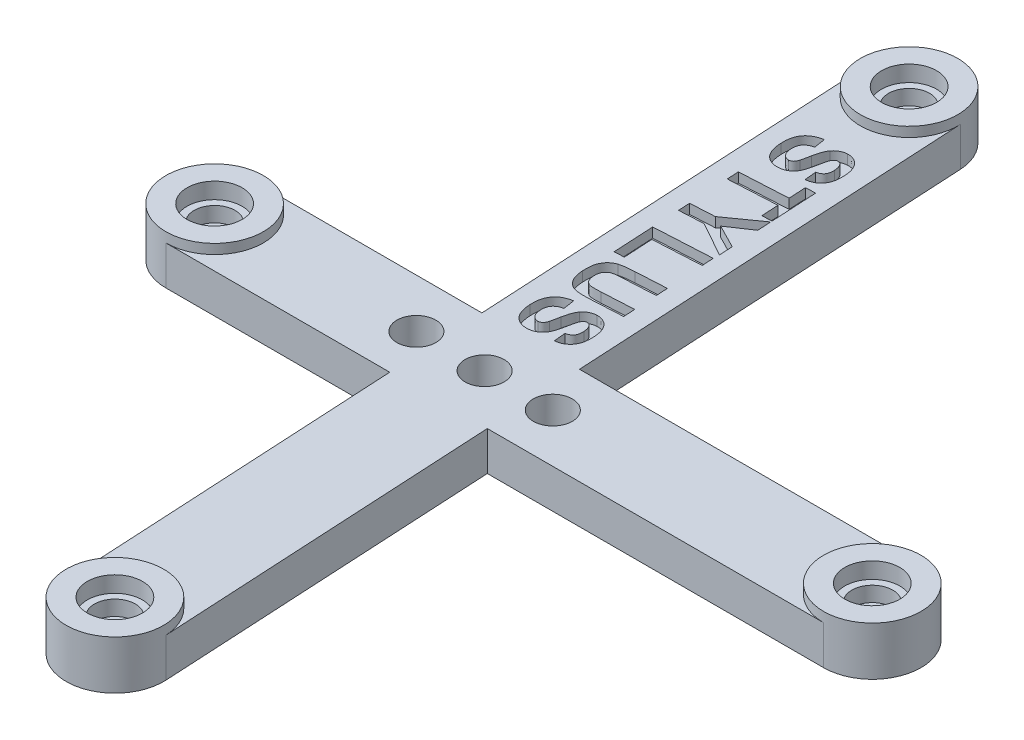
from build123d import *

# Parameters (mm, degrees)
BOSS_EXTRUDE1_DEPTH = 4
SKETCH2_R           = 5
BOSS_EXTRUDE2_DEPTH = 1
SKETCH3_R           = 1.5
CUT_EXTRUDE1_DEPTH  = 6
SKETCH4_R           = 2.1
CUT_EXTRUDE2_DEPTH  = 3.2
SKETCH5_R           = 2.825
CUT_EXTRUDE3_DEPTH  = 1.65
SKETCH6_R           = 2
CUT_EXTRUDE4_DEPTH  = 5
CUT_EXTRUDE5_DEPTH  = 1


with BuildPart() as part:
    # Sketch1 → Boss-Extrude1 (new body)
    with BuildSketch(Plane(origin=(0, 0, 0), x_dir=(1, 0, 0), z_dir=(0, 1, 0))):
        with BuildLine():
            Line((-9.628086501, 85.876730552), (-7.434079947, 45.10198834))
            Line((-7.434079947, 45.10198834), (-29.867807027, 45.10198834))
            ThreePointArc((-29.867807027, 45.10198834), (-34.867807027, 40.10198834), (-29.867807027, 35.10198834))
            Line((-29.867807027, 35.10198834), (-6.896000137, 35.10198834))
            Line((-6.896000137, 35.10198834), (-4.992777433, -0.268651273))
            ThreePointArc((-4.992777433, -0.268651273), (0.268651273, -4.992777433), (4.992777433, 0.268651273))
            Line((4.992777433, 0.268651273), (3.118465894, 35.10198834))
            Line((3.118465894, 35.10198834), (37.632192973, 35.10198834))
            ThreePointArc((37.632192973, 35.10198834), (42.632192973, 40.10198834), (37.632192973, 45.10198834))
            Line((37.632192973, 45.10198834), (2.580386084, 45.10198834))
            Line((2.580386084, 45.10198834), (0.357468365, 86.414033099))
            ThreePointArc((0.357468365, 86.414033099), (-4.903960341, 91.138159258), (-9.628086501, 85.876730552))
        make_face()
    extrude(amount=BOSS_EXTRUDE1_DEPTH)

    # Sketch2 → Boss-Extrude2 (add)
    with BuildSketch(Plane(origin=(0, 4, 0), x_dir=(1, 0, 0), z_dir=(0, 1, 0))):
        with Locations((-4.635309068, 86.145381825)):
            Circle(SKETCH2_R)
        with Locations((-29.867807027, 40.10198834)):
            Circle(SKETCH2_R)
        with Locations((37.632192973, 40.10198834)):
            Circle(SKETCH2_R)
        Circle(SKETCH2_R)
    extrude(amount=BOSS_EXTRUDE2_DEPTH)

    # Sketch3 → Cut-Extrude1 (cut, through all)
    with BuildSketch(Plane(origin=(0, 5, 0), x_dir=(1, 0, 0), z_dir=(0, 1, 0))):
        with Locations((-29.867807027, 40.10198834)):
            Circle(SKETCH3_R)
        with Locations((-4.635309068, 86.145381825)):
            Circle(SKETCH3_R)
        with Locations((37.632192973, 40.10198834)):
            Circle(SKETCH3_R)
        Circle(SKETCH3_R)
    extrude(amount=-CUT_EXTRUDE1_DEPTH, mode=Mode.SUBTRACT)

    # Sketch4 → Cut-Extrude2 (cut)
    with BuildSketch(Plane(origin=(0, 5, 0), x_dir=(1, 0, 0), z_dir=(0, 1, 0))):
        with Locations((-4.635309068, 86.145381825)):
            Circle(SKETCH4_R)
        with Locations((-29.867807027, 40.10198834)):
            Circle(SKETCH4_R)
        with Locations((37.632192973, 40.10198834)):
            Circle(SKETCH4_R)
        Circle(SKETCH4_R)
    extrude(amount=-CUT_EXTRUDE2_DEPTH, mode=Mode.SUBTRACT)

    # Sketch5 → Cut-Extrude3 (cut)
    with BuildSketch(Plane(origin=(0, 5, 0), x_dir=(1, 0, 0), z_dir=(0, 1, 0))):
        with Locations((-4.635309068, 86.145381825)):
            Circle(SKETCH5_R)
        with Locations((-29.867807027, 40.10198834)):
            Circle(SKETCH5_R)
        with Locations((37.632192973, 40.10198834)):
            Circle(SKETCH5_R)
        Circle(SKETCH5_R)
    extrude(amount=-CUT_EXTRUDE3_DEPTH, mode=Mode.SUBTRACT)

    # Sketch6 → Cut-Extrude4 (cut, through all)
    with BuildSketch(Plane(origin=(0, 4, 0), x_dir=(1, 0, 0), z_dir=(0, 1, 0))):
        with Locations((-2.157807027, 40.10198834)):
            Circle(SKETCH6_R)
        with Locations((4.842192973, 40.10198834)):
            Circle(SKETCH6_R)
        with Locations((-9.157807027, 40.10198834)):
            Circle(SKETCH6_R)
    extrude(amount=-CUT_EXTRUDE4_DEPTH, mode=Mode.SUBTRACT)

    # Sketch7 → Cut-Extrude5 (cut)
    with BuildSketch(Plane(origin=(0, 4, 0), x_dir=(1, 0, 0), z_dir=(0, 1, 0))):
        with BuildLine():
            Line((-5.264074732, 78.076081163), (-5.088593962, 76.913821548))
            add(Edge.make_bspline(
                [(-5.088593962, 76.913821548), (-5.135633909, 76.901996916), (-5.226917461, 76.87905058), (-5.357629783, 76.835678309), (-5.47795541, 76.785016988), (-5.588836743, 76.729004059), (-5.689252964, 76.666032193), (-5.77984549, 76.597777554), (-5.86018822, 76.522546335), (-5.929979434, 76.440461103), (-5.990516975, 76.352298032), (-6.041369582, 76.257461765), (-6.083163077, 76.156279746), (-6.11731267, 76.048674834), (-6.141070944, 75.934283827), (-6.155035224, 75.81322286), (-6.161283992, 75.685896766), (-6.158517857, 75.598917581), (-6.157103578, 75.554446548)],
                knots=[0, 0, 0, 0, 0.000145477, 0.000282307, 0.00041267, 0.000536841, 0.000654562, 0.000767785, 0.000876624, 0.000984046, 0.001090395, 0.001196872, 0.001306247, 0.001418387, 0.001535072, 0.001656127, 0.001783672, 0.001917108, 0.001917108, 0.001917108, 0.001917108], degree=3))
            add(Edge.make_bspline(
                [(-6.157103578, 75.554446548), (-6.154283879, 75.507486495), (-6.148840724, 75.416834661), (-6.128067459, 75.285895723), (-6.104701418, 75.16359605), (-6.069780222, 75.051206914), (-6.03132776, 74.947587235), (-5.983447645, 74.853475863), (-5.929003994, 74.768571214), (-5.866717542, 74.69369055), (-5.801446431, 74.627703589), (-5.732029347, 74.571938925), (-5.66101456, 74.525292335), (-5.588678173, 74.485186043), (-5.512386235, 74.458541558), (-5.435291684, 74.438679966), (-5.355679262, 74.428556946), (-5.302156512, 74.429942613), (-5.274892039, 74.430648471)],
                knots=[0, 0, 0, 0, 0.00014104, 0.000272265, 0.000397432, 0.000514167, 0.000624882, 0.000728624, 0.000830305, 0.000926796, 0.001020284, 0.00110832, 0.001193326, 0.001275057, 0.001355666, 0.001434957, 0.001513671, 0.001595402, 0.001595402, 0.001595402, 0.001595402], degree=3))
            add(Edge.make_bspline(
                [(-5.274892039, 74.430648471), (-5.241062727, 74.433964345), (-5.17514334, 74.440425617), (-5.081087182, 74.468222598), (-4.996373817, 74.512954554), (-4.918400714, 74.572657176), (-4.850505115, 74.654339099), (-4.787332788, 74.755336833), (-4.733234893, 74.880193602), (-4.703921355, 74.972023734), (-4.688353578, 75.020792702)],
                knots=[0, 0, 0, 0, 0.000101824, 0.000198412, 0.000291954, 0.000387882, 0.000491003, 0.000608724, 0.000744307, 0.000897861, 0.000897861, 0.000897861, 0.000897861], degree=3))
            add(Edge.make_bspline(
                [(-4.688353578, 75.020792702), (-4.682638545, 75.041598823), (-4.669819444, 75.088267986), (-4.650964673, 75.167396042), (-4.627370712, 75.263202894), (-4.604721286, 75.377072426), (-4.576255378, 75.507018603), (-4.546388777, 75.6540992), (-4.514033943, 75.818383043), (-4.491979151, 75.933841844), (-4.480420886, 75.994350394)],
                knots=[0, 0, 0, 0, 6.4726e-05, 0.000145183, 0.000244011, 0.000360697, 0.000493415, 0.000643097, 0.000810928, 0.000995735, 0.000995735, 0.000995735, 0.000995735], degree=3))
            add(Edge.make_bspline(
                [(-4.480420886, 75.994350394), (-4.46446382, 76.072976278), (-4.433585579, 76.225123864), (-4.381315452, 76.443493903), (-4.323591993, 76.644049764), (-4.261236287, 76.826479611), (-4.195849085, 76.991970341), (-4.124544422, 77.139226702), (-4.050410664, 77.269709775), (-3.993190265, 77.346214659), (-3.965997809, 77.382571548)],
                knots=[0, 0, 0, 0, 0.000240676, 0.000465728, 0.000673421, 0.000866508, 0.001043945, 0.001206827, 0.001357106, 0.001493194, 0.001493194, 0.001493194, 0.001493194], degree=3))
            add(Edge.make_bspline(
                [(-3.965997809, 77.382571548), (-3.927197208, 77.428237668), (-3.850748758, 77.518213185), (-3.723135312, 77.637309851), (-3.587228969, 77.738778577), (-3.445382719, 77.8252605), (-3.294434318, 77.892693246), (-3.136642474, 77.944503516), (-2.970617114, 77.980303339), (-2.856791274, 77.989616342), (-2.798930501, 77.994350394)],
                knots=[0, 0, 0, 0, 0.000179666, 0.000353995, 0.000522264, 0.000687785, 0.000851317, 0.001017035, 0.001185347, 0.00135936, 0.00135936, 0.00135936, 0.00135936], degree=3))
            add(Edge.make_bspline(
                [(-2.798930501, 77.994350394), (-2.723849216, 77.995628786), (-2.574651269, 77.998169144), (-2.353671463, 77.957896459), (-2.138249798, 77.889712295), (-1.967301794, 77.803691519), (-1.835534622, 77.721837321), (-1.7409826, 77.651557373), (-1.65265926, 77.573483017), (-1.56869441, 77.488705584), (-1.490901703, 77.396161414), (-1.418129022, 77.296008477), (-1.352918597, 77.187508117), (-1.269151141, 77.032890837), (-1.181348523, 76.820147084), (-1.102999497, 76.541708002), (-1.047200029, 76.237422326), (-1.030920182, 76.025030016), (-1.022488193, 75.915023471)],
                knots=[0, 0, 0, 0, 0.000224789, 0.000446689, 0.000670189, 0.000900786, 0.001018507, 0.001135335, 0.001253716, 0.001371854, 0.001492968, 0.001616064, 0.001742837, 0.001872433, 0.002143421, 0.00243102, 0.002738909, 0.003069715, 0.003069715, 0.003069715, 0.003069715], degree=3))
            add(Edge.make_bspline(
                [(-1.022488193, 75.915023471), (-1.018848026, 75.824490789), (-1.011775872, 75.64860297), (-1.021843541, 75.392781545), (-1.046713158, 75.153403044), (-1.086543329, 74.929838904), (-1.145372489, 74.72301954), (-1.220313906, 74.532622284), (-1.310025504, 74.358077577), (-1.41779823, 74.201606084), (-1.538666436, 74.061296008), (-1.67148342, 73.93709025), (-1.814949231, 73.828172882), (-1.970046806, 73.735947364), (-2.136966403, 73.661635474), (-2.314548432, 73.602895492), (-2.502745628, 73.558578712), (-2.632851135, 73.543900002), (-2.699170886, 73.536417702)],
                knots=[0, 0, 0, 0, 0.00027173, 0.00052792, 0.000767236, 0.000993316, 0.001208272, 0.001411155, 0.0016063, 0.001795659, 0.001979738, 0.002160862, 0.00234019, 0.002519111, 0.002700948, 0.002887187, 0.003079615, 0.003279688, 0.003279688, 0.003279688, 0.003279688], degree=3))
            Line((-2.699170886, 73.536417702), (-2.816959347, 74.73473501))
            add(Edge.make_bspline(
                [(-2.816959347, 74.73473501), (-2.780337673, 74.743360156), (-2.709169164, 74.760121782), (-2.608163334, 74.794279487), (-2.515222471, 74.832484993), (-2.430665222, 74.875731346), (-2.354541065, 74.923899197), (-2.286303539, 74.976867689), (-2.227305444, 75.036096387), (-2.176081386, 75.100611762), (-2.132179589, 75.171610177), (-2.095231837, 75.249443153), (-2.064987643, 75.335275634), (-2.040817032, 75.428058178), (-2.026343999, 75.529299025), (-2.01491158, 75.637098503), (-2.011468, 75.752792581), (-2.014775012, 75.832101273), (-2.016478578, 75.872956163)],
                knots=[0, 0, 0, 0, 0.000112814, 0.000219237, 0.000319459, 0.000414068, 0.000503763, 0.000589361, 0.00067265, 0.000753929, 0.000835977, 0.000922532, 0.001011872, 0.001108655, 0.00120963, 0.001318343, 0.001433784, 0.001556433, 0.001556433, 0.001556433, 0.001556433], degree=3))
            add(Edge.make_bspline(
                [(-2.016478578, 75.872956163), (-2.019778161, 75.915442866), (-2.026174742, 75.997807714), (-2.040566244, 76.117855194), (-2.066149381, 76.229697532), (-2.093020208, 76.335364729), (-2.130805135, 76.432152471), (-2.170451836, 76.523387542), (-2.219836084, 76.605880274), (-2.25763471, 76.65611564), (-2.276093962, 76.680648471)],
                knots=[0, 0, 0, 0, 0.000127862, 0.000247874, 0.000362209, 0.000471841, 0.000574533, 0.000673508, 0.000769977, 0.000862055, 0.000862055, 0.000862055, 0.000862055], degree=3))
            add(Edge.make_bspline(
                [(-2.276093962, 76.680648471), (-2.301339888, 76.708430797), (-2.350153148, 76.762148212), (-2.442605465, 76.819625061), (-2.546522395, 76.850717745), (-2.618839257, 76.851116954), (-2.655901655, 76.851321548)],
                knots=[0, 0, 0, 0, 0.000112185, 0.000216911, 0.000322249, 0.000432989, 0.000432989, 0.000432989, 0.000432989], degree=3))
            add(Edge.make_bspline(
                [(-2.655901655, 76.851321548), (-2.68996058, 76.847387586), (-2.756999949, 76.839644231), (-2.851537066, 76.798371909), (-2.93703276, 76.73643314), (-2.983120813, 76.681370106), (-3.006863193, 76.65300424)],
                knots=[0, 0, 0, 0, 0.000102354, 0.000201467, 0.000305564, 0.000416167, 0.000416167, 0.000416167, 0.000416167], degree=3))
            add(Edge.make_bspline(
                [(-3.006863193, 76.65300424), (-3.022257152, 76.630097981), (-3.056064788, 76.579792111), (-3.098332115, 76.488673593), (-3.140825454, 76.378447567), (-3.184435631, 76.247869), (-3.225609857, 76.096825648), (-3.266368159, 75.925155002), (-3.306870634, 75.733519769), (-3.346124793, 75.526861138), (-3.385226855, 75.317791113), (-3.425576807, 75.117143069), (-3.469415465, 74.931513763), (-3.511997366, 74.758811454), (-3.557281687, 74.600830361), (-3.604877217, 74.457303495), (-3.650602013, 74.327039128), (-3.715646251, 74.175221354), (-3.806758713, 74.002731155), (-3.939442949, 73.817946848), (-4.094257218, 73.655098917), (-4.239497006, 73.536833442), (-4.366879167, 73.455800197), (-4.46869203, 73.40106562), (-4.576404846, 73.35426897), (-4.691068745, 73.316405039), (-4.810550061, 73.281826775), (-4.936945284, 73.257519625), (-5.068912454, 73.23882872), (-5.159048029, 73.232940817), (-5.205180501, 73.229927317)],
                knots=[0, 0, 0, 0, 8.2688e-05, 0.000181597, 0.000300339, 0.000437168, 0.000594344, 0.000769842, 0.000966443, 0.001181893, 0.001400884, 0.001604545, 0.001795802, 0.00197304, 0.002138137, 0.002288651, 0.002426663, 0.00255213, 0.002783889, 0.003010378, 0.003232278, 0.003456217, 0.003570248, 0.003684784, 0.003802677, 0.003922025, 0.00404684, 0.004175541, 0.004307785, 0.004446429, 0.004446429, 0.004446429, 0.004446429], degree=3))
            add(Edge.make_bspline(
                [(-5.205180501, 73.229927317), (-5.24764681, 73.228544502), (-5.331818879, 73.225803638), (-5.457604219, 73.231948789), (-5.581790982, 73.247504983), (-5.704560197, 73.273168383), (-5.825868302, 73.306702444), (-5.945747386, 73.348839156), (-6.06341828, 73.401111939), (-6.179551764, 73.460392748), (-6.291342843, 73.528967461), (-6.397428335, 73.605679846), (-6.495519387, 73.691374499), (-6.587925674, 73.783343151), (-6.67343461, 73.883189745), (-6.751449992, 73.991566885), (-6.822245306, 74.107627013), (-6.887804994, 74.230438629), (-6.945107352, 74.362156673), (-6.996856464, 74.501803023), (-7.042326136, 74.649931597), (-7.082067443, 74.805881281), (-7.114357706, 74.970471887), (-7.140326215, 75.142947471), (-7.161518668, 75.324088488), (-7.168932646, 75.447824755), (-7.172728578, 75.511177317)],
                knots=[0, 0, 0, 0, 0.000127427, 0.000252571, 0.000377351, 0.000502519, 0.000628491, 0.000754699, 0.000883327, 0.001014491, 0.001145594, 0.001276378, 0.001406746, 0.001535929, 0.001667209, 0.001800644, 0.001936078, 0.002074794, 0.002217944, 0.002366638, 0.002521369, 0.002682575, 0.002849227, 0.003024312, 0.003205755, 0.003396118, 0.003396118, 0.003396118, 0.003396118], degree=3))
            add(Edge.make_bspline(
                [(-7.172728578, 75.511177317), (-7.176470143, 75.602515725), (-7.183758197, 75.780430366), (-7.172186826, 76.039890823), (-7.145630318, 76.284384679), (-7.099659229, 76.512568519), (-7.038994428, 76.726313513), (-6.959320717, 76.923926282), (-6.863348298, 77.107193138), (-6.747774071, 77.273433375), (-6.618011379, 77.426512666), (-6.469521253, 77.561909533), (-6.308306593, 77.686332754), (-6.128841586, 77.792216721), (-5.93559184, 77.887104059), (-5.726207089, 77.965782858), (-5.500942976, 78.029927488), (-5.344467809, 78.060416607), (-5.264074732, 78.076081163)],
                knots=[0, 0, 0, 0, 0.000274133, 0.000533974, 0.000778331, 0.001011219, 0.00123146, 0.001443939, 0.001649327, 0.001850695, 0.002050156, 0.002250026, 0.002452435, 0.002660006, 0.002873948, 0.003097622, 0.003330079, 0.003575707, 0.003575707, 0.003575707, 0.003575707], degree=3))
        make_face()
        Polygon((-6.812645629, 70.798023853), (-1.87153986, 71.066052699), (-1.967693706, 72.830475776), (-0.961684091, 72.884562315), (-0.705674475, 68.159802699), (-1.711684091, 68.105716161), (-1.806636014, 69.865331545), (-6.747741783, 69.597302699), align=None)
        Polygon((-6.527842029, 65.506078691), (-4.025438182, 65.641895998), (-0.699717029, 68.006078691), (-0.622793952, 66.598626768), (-2.900438182, 65.07218446), (-0.472553567, 63.828194075), (-0.398034336, 62.444780614), (-3.967745875, 64.443578691), (-6.462938182, 64.308963306), align=None)
        Polygon((-6.313191772, 61.504463688), (-0.415355234, 61.824175227), (-0.350451387, 60.623454073), (-5.24588408, 60.357829073), (-5.084826387, 57.37225215), (-6.087230234, 57.318165611), align=None)
        with BuildLine():
            Line((-0.095695864, 56.797855064), (-0.030792018, 55.59713391))
            Line((-0.030792018, 55.59713391), (-3.251945864, 55.422855064))
            add(Edge.make_bspline(
                [(-3.251945864, 55.422855064), (-3.312844647, 55.419278863), (-3.429452808, 55.412431202), (-3.595794567, 55.402197763), (-3.745196998, 55.389885887), (-3.877404027, 55.37784669), (-3.99294871, 55.36654252), (-4.091405677, 55.352840739), (-4.173498004, 55.340798347), (-4.221951832, 55.329382023), (-4.243532402, 55.324297372)],
                knots=[0, 0, 0, 0, 0.000183012, 0.000350429, 0.000499952, 0.000632708, 0.000748717, 0.000848158, 0.000930951, 0.000997438, 0.000997438, 0.000997438, 0.000997438], degree=3))
            add(Edge.make_bspline(
                [(-4.243532402, 55.324297372), (-4.301264155, 55.305916711), (-4.414523662, 55.269857101), (-4.568694812, 55.180895522), (-4.702567351, 55.066343863), (-4.796047988, 54.950869421), (-4.858238422, 54.846759565), (-4.899485137, 54.76181204), (-4.931097238, 54.669467341), (-4.958467207, 54.5722016), (-4.975403485, 54.467748052), (-4.988181996, 54.35748541), (-4.990967269, 54.240546601), (-4.988689912, 54.160826378), (-4.987522787, 54.119970449)],
                knots=[0, 0, 0, 0, 0.000181347, 0.000355771, 0.00052968, 0.000707443, 0.000798552, 0.000893168, 0.000990108, 0.001090991, 0.001195917, 0.001307145, 0.001423787, 0.001546407, 0.001546407, 0.001546407, 0.001546407], degree=3))
            add(Edge.make_bspline(
                [(-4.987522787, 54.119970449), (-4.984973868, 54.078633815), (-4.980031337, 53.998479212), (-4.962091347, 53.883150256), (-4.941828269, 53.775440019), (-4.911839698, 53.676739947), (-4.879465321, 53.584613638), (-4.837802789, 53.501969972), (-4.792688026, 53.425983687), (-4.722353314, 53.339883777), (-4.62594107, 53.247772097), (-4.496395076, 53.162195904), (-4.356646162, 53.101378708), (-4.230021462, 53.076838149), (-4.120316224, 53.065870255), (-4.024397054, 53.0621827), (-3.916249039, 53.057609523), (-3.795607816, 53.05882397), (-3.6625852, 53.059412308), (-3.517138179, 53.063336565), (-3.35927434, 53.069309061), (-3.249936556, 53.074962065), (-3.193051633, 53.077903141)],
                knots=[0, 0, 0, 0, 0.000124171, 0.000240776, 0.000349913, 0.000452605, 0.000549954, 0.000642408, 0.00072981, 0.000814467, 0.000975152, 0.001127829, 0.001278075, 0.001429178, 0.001512536, 0.00160881, 0.001717043, 0.001837236, 0.001970655, 0.002116132, 0.002273699, 0.002444579, 0.002444579, 0.002444579, 0.002444579], degree=3))
            Line((-3.193051633, 53.077903141), (0.096611828, 53.255787756))
            Line((0.096611828, 53.255787756), (0.161515675, 52.055066603))
            Line((0.161515675, 52.055066603), (-2.962282402, 51.885595449))
            add(Edge.make_bspline(
                [(-2.962282402, 51.885595449), (-3.048411234, 51.88138223), (-3.213822553, 51.8732907), (-3.452225051, 51.864931775), (-3.670984007, 51.859679972), (-3.870575286, 51.859228928), (-4.050868762, 51.864710547), (-4.212058614, 51.870925802), (-4.353713373, 51.882400136), (-4.513893436, 51.90472713), (-4.695099077, 51.942713849), (-4.895645628, 52.013385072), (-5.081337045, 52.103170601), (-5.250490798, 52.2167534), (-5.404428068, 52.352216787), (-5.541614445, 52.511916511), (-5.666351333, 52.692395002), (-5.756843358, 52.860058594), (-5.819638599, 53.006915712), (-5.863717121, 53.126558449), (-5.899981637, 53.255909749), (-5.933940902, 53.393190332), (-5.961739948, 53.539626698), (-5.982237967, 53.694646578), (-6.00134451, 53.858013986), (-6.008103205, 53.970082978), (-6.011561248, 54.027422372)],
                knots=[0, 0, 0, 0, 0.000258693, 0.000496822, 0.000715625, 0.000915144, 0.001095497, 0.001256716, 0.001399051, 0.001521606, 0.001741798, 0.001953145, 0.002157945, 0.002358957, 0.00256248, 0.002771203, 0.002988914, 0.003219614, 0.003341294, 0.003467907, 0.003601802, 0.003744061, 0.003892098, 0.004048648, 0.004213101, 0.004385395, 0.004385395, 0.004385395, 0.004385395], degree=3))
            add(Edge.make_bspline(
                [(-6.011561248, 54.027422372), (-6.014854642, 54.096316027), (-6.021247447, 54.230045458), (-6.022505585, 54.424512698), (-6.01632591, 54.606507378), (-6.004999151, 54.775815532), (-5.98599134, 54.932757393), (-5.959543059, 55.076757466), (-5.927742967, 55.208785947), (-5.875154963, 55.365184542), (-5.795396728, 55.542219513), (-5.685475676, 55.735989379), (-5.558409068, 55.907288633), (-5.416041971, 56.055100388), (-5.263882467, 56.181074507), (-5.104779125, 56.285188022), (-4.941839475, 56.370136778), (-4.827456799, 56.407886625), (-4.771176633, 56.426460833)],
                knots=[0, 0, 0, 0, 0.000206902, 0.000401617, 0.000583207, 0.000753104, 0.000910533, 0.001057167, 0.001192136, 0.001317563, 0.00155163, 0.001773462, 0.001984761, 0.002189629, 0.002387687, 0.002576037, 0.002759333, 0.00293688, 0.00293688, 0.00293688, 0.00293688], degree=3))
            add(Edge.make_bspline(
                [(-4.771176633, 56.426460833), (-4.726801591, 56.438467012), (-4.632962481, 56.463856264), (-4.483297246, 56.495620303), (-4.318027331, 56.524170882), (-4.137651667, 56.550399147), (-3.942143427, 56.574592823), (-3.730864692, 56.594468772), (-3.504524199, 56.612898631), (-3.348123981, 56.621532985), (-3.267570864, 56.625980064)],
                knots=[0, 0, 0, 0, 0.000137892, 0.000291597, 0.000458768, 0.000640985, 0.000838368, 0.001049694, 0.001277572, 0.001519589, 0.001519589, 0.001519589, 0.001519589], degree=3))
            Line((-3.267570864, 56.625980064), (-0.095695864, 56.797855064))
        make_face()
        with BuildLine():
            Line((-3.800958567, 50.884647145), (-3.625477798, 49.722387529))
            add(Edge.make_bspline(
                [(-3.625477798, 49.722387529), (-3.672517744, 49.710562897), (-3.763801296, 49.687616561), (-3.894513618, 49.644244291), (-4.014839245, 49.59358297), (-4.125720578, 49.537570041), (-4.226136799, 49.474598175), (-4.316729325, 49.406343536), (-4.397072055, 49.331112316), (-4.466863269, 49.249027085), (-4.52740081, 49.160864013), (-4.578253418, 49.066027747), (-4.620046913, 48.964845727), (-4.654196505, 48.857240815), (-4.67795478, 48.742849809), (-4.691919059, 48.621788842), (-4.698167827, 48.494462747), (-4.695401692, 48.407483562), (-4.693987413, 48.363012529)],
                knots=[0, 0, 0, 0, 0.000145477, 0.000282307, 0.00041267, 0.000536841, 0.000654562, 0.000767785, 0.000876624, 0.000984046, 0.001090395, 0.001196872, 0.001306247, 0.001418387, 0.001535072, 0.001656127, 0.001783672, 0.001917108, 0.001917108, 0.001917108, 0.001917108], degree=3))
            add(Edge.make_bspline(
                [(-4.693987413, 48.363012529), (-4.691167714, 48.316052476), (-4.685724559, 48.225400643), (-4.664951294, 48.094461704), (-4.641585253, 47.972162031), (-4.606664057, 47.859772895), (-4.568211595, 47.756153217), (-4.52033148, 47.662041845), (-4.465887829, 47.577137195), (-4.403601377, 47.502256532), (-4.338330266, 47.436269571), (-4.268913182, 47.380504906), (-4.197898395, 47.333858317), (-4.125562008, 47.293752024), (-4.04927007, 47.267107539), (-3.972175519, 47.247245947), (-3.892563097, 47.237122927), (-3.839040347, 47.238508594), (-3.811775874, 47.239214452)],
                knots=[0, 0, 0, 0, 0.00014104, 0.000272265, 0.000397432, 0.000514167, 0.000624882, 0.000728624, 0.000830305, 0.000926796, 0.001020284, 0.00110832, 0.001193326, 0.001275057, 0.001355666, 0.001434957, 0.001513671, 0.001595402, 0.001595402, 0.001595402, 0.001595402], degree=3))
            add(Edge.make_bspline(
                [(-3.811775874, 47.239214452), (-3.777946562, 47.242530327), (-3.712027175, 47.248991598), (-3.617971017, 47.276788579), (-3.533257652, 47.321520535), (-3.455284549, 47.381223158), (-3.38738895, 47.462905081), (-3.324216623, 47.563902814), (-3.270118728, 47.688759583), (-3.24080519, 47.780589715), (-3.225237413, 47.829358683)],
                knots=[0, 0, 0, 0, 0.000101824, 0.000198412, 0.000291954, 0.000387882, 0.000491003, 0.000608724, 0.000744307, 0.000897861, 0.000897861, 0.000897861, 0.000897861], degree=3))
            add(Edge.make_bspline(
                [(-3.225237413, 47.829358683), (-3.21952238, 47.850164804), (-3.206703279, 47.896833967), (-3.187848508, 47.975962023), (-3.164254547, 48.071768876), (-3.141605121, 48.185638408), (-3.113139214, 48.315584585), (-3.083272612, 48.462665182), (-3.050917778, 48.626949025), (-3.028862986, 48.742407825), (-3.017304721, 48.802916376)],
                knots=[0, 0, 0, 0, 6.4726e-05, 0.000145183, 0.000244011, 0.000360697, 0.000493415, 0.000643097, 0.000810928, 0.000995735, 0.000995735, 0.000995735, 0.000995735], degree=3))
            add(Edge.make_bspline(
                [(-3.017304721, 48.802916376), (-3.001347655, 48.881542259), (-2.970469414, 49.033689845), (-2.918199287, 49.252059885), (-2.860475828, 49.452615746), (-2.798120122, 49.635045593), (-2.73273292, 49.800536322), (-2.661428257, 49.947792683), (-2.587294499, 50.078275756), (-2.5300741, 50.15478064), (-2.502881644, 50.191137529)],
                knots=[0, 0, 0, 0, 0.000240676, 0.000465728, 0.000673421, 0.000866508, 0.001043945, 0.001206827, 0.001357106, 0.001493194, 0.001493194, 0.001493194, 0.001493194], degree=3))
            add(Edge.make_bspline(
                [(-2.502881644, 50.191137529), (-2.464081043, 50.23680365), (-2.387632593, 50.326779167), (-2.260019147, 50.445875832), (-2.124112804, 50.547344559), (-1.982266554, 50.633826482), (-1.831318153, 50.701259228), (-1.673526309, 50.753069497), (-1.507500949, 50.788869321), (-1.393675109, 50.798182323), (-1.335814336, 50.802916376)],
                knots=[0, 0, 0, 0, 0.000179666, 0.000353995, 0.000522264, 0.000687785, 0.000851317, 0.001017035, 0.001185347, 0.00135936, 0.00135936, 0.00135936, 0.00135936], degree=3))
            add(Edge.make_bspline(
                [(-1.335814336, 50.802916376), (-1.260733051, 50.804194767), (-1.111535104, 50.806735125), (-0.890555298, 50.76646244), (-0.675133633, 50.698278276), (-0.504185629, 50.6122575), (-0.372418457, 50.530403303), (-0.277866435, 50.460123354), (-0.189543095, 50.382048998), (-0.105578245, 50.297271566), (-0.027785538, 50.204727396), (0.044987143, 50.104574458), (0.110197568, 49.996074098), (0.193965024, 49.841456818), (0.281767642, 49.628713065), (0.360116668, 49.350273984), (0.415916136, 49.045988308), (0.432195983, 48.833595997), (0.440627972, 48.723589452)],
                knots=[0, 0, 0, 0, 0.000224789, 0.000446689, 0.000670189, 0.000900786, 0.001018507, 0.001135335, 0.001253716, 0.001371854, 0.001492968, 0.001616064, 0.001742837, 0.001872433, 0.002143421, 0.00243102, 0.002738909, 0.003069715, 0.003069715, 0.003069715, 0.003069715], degree=3))
            add(Edge.make_bspline(
                [(0.440627972, 48.723589452), (0.444268139, 48.63305677), (0.451340293, 48.457168952), (0.441272624, 48.201347526), (0.416403007, 47.961969025), (0.376572836, 47.738404886), (0.317743676, 47.531585521), (0.242802259, 47.341188265), (0.153090661, 47.166643559), (0.045317935, 47.010172065), (-0.075550271, 46.869861989), (-0.208367255, 46.745656232), (-0.351833066, 46.636738863), (-0.506930641, 46.544513346), (-0.673850238, 46.470201456), (-0.851432267, 46.411461474), (-1.039629463, 46.367144693), (-1.16973497, 46.352465983), (-1.236054721, 46.344983683)],
                knots=[0, 0, 0, 0, 0.00027173, 0.00052792, 0.000767236, 0.000993316, 0.001208272, 0.001411155, 0.0016063, 0.001795659, 0.001979738, 0.002160862, 0.00234019, 0.002519111, 0.002700948, 0.002887187, 0.003079615, 0.003279688, 0.003279688, 0.003279688, 0.003279688], degree=3))
            Line((-1.236054721, 46.344983683), (-1.353843182, 47.543300991))
            add(Edge.make_bspline(
                [(-1.353843182, 47.543300991), (-1.317221508, 47.551926137), (-1.246052999, 47.568687763), (-1.145047169, 47.602845469), (-1.052106306, 47.641050974), (-0.967549058, 47.684297328), (-0.8914249, 47.732465179), (-0.823187374, 47.785433671), (-0.764189279, 47.844662369), (-0.712965222, 47.909177743), (-0.669063424, 47.980176158), (-0.632115672, 48.058009135), (-0.601871478, 48.143841615), (-0.577700867, 48.23662416), (-0.563227834, 48.337865006), (-0.551795415, 48.445664485), (-0.548351835, 48.561358562), (-0.551658847, 48.640667255), (-0.553362413, 48.681522145)],
                knots=[0, 0, 0, 0, 0.000112814, 0.000219237, 0.000319459, 0.000414068, 0.000503763, 0.000589361, 0.00067265, 0.000753929, 0.000835977, 0.000922532, 0.001011872, 0.001108655, 0.00120963, 0.001318343, 0.001433784, 0.001556433, 0.001556433, 0.001556433, 0.001556433], degree=3))
            add(Edge.make_bspline(
                [(-0.553362413, 48.681522145), (-0.556661996, 48.724008848), (-0.563058577, 48.806373696), (-0.577450079, 48.926421175), (-0.603033216, 49.038263513), (-0.629904043, 49.143930711), (-0.667688971, 49.240718453), (-0.707335671, 49.331953523), (-0.756719919, 49.414446255), (-0.794518545, 49.464681622), (-0.812977798, 49.489214452)],
                knots=[0, 0, 0, 0, 0.000127862, 0.000247874, 0.000362209, 0.000471841, 0.000574533, 0.000673508, 0.000769977, 0.000862055, 0.000862055, 0.000862055, 0.000862055], degree=3))
            add(Edge.make_bspline(
                [(-0.812977798, 49.489214452), (-0.838223723, 49.516996778), (-0.887036983, 49.570714194), (-0.9794893, 49.628191043), (-1.08340623, 49.659283726), (-1.155723092, 49.659682935), (-1.19278549, 49.659887529)],
                knots=[0, 0, 0, 0, 0.000112185, 0.000216911, 0.000322249, 0.000432989, 0.000432989, 0.000432989, 0.000432989], degree=3))
            add(Edge.make_bspline(
                [(-1.19278549, 49.659887529), (-1.226844415, 49.655953567), (-1.293883784, 49.648210213), (-1.388420901, 49.60693789), (-1.473916595, 49.544999122), (-1.520004648, 49.489936087), (-1.543747028, 49.461570222)],
                knots=[0, 0, 0, 0, 0.000102354, 0.000201467, 0.000305564, 0.000416167, 0.000416167, 0.000416167, 0.000416167], degree=3))
            add(Edge.make_bspline(
                [(-1.543747028, 49.461570222), (-1.559140987, 49.438663963), (-1.592948623, 49.388358093), (-1.63521595, 49.297239575), (-1.677709289, 49.187013549), (-1.721319466, 49.056434982), (-1.762493692, 48.90539163), (-1.803251995, 48.733720983), (-1.843754469, 48.542085751), (-1.883008628, 48.335427119), (-1.92211069, 48.126357094), (-1.962460642, 47.925709051), (-2.0062993, 47.740079745), (-2.048881201, 47.567377436), (-2.094165522, 47.409396343), (-2.141761052, 47.265869476), (-2.187485848, 47.135605109), (-2.252530086, 46.983787335), (-2.343642548, 46.811297137), (-2.476326784, 46.626512829), (-2.631141053, 46.463664899), (-2.776380841, 46.345399424), (-2.903763002, 46.264366178), (-3.005575865, 46.209631602), (-3.113288681, 46.162834951), (-3.22795258, 46.12497102), (-3.347433896, 46.090392757), (-3.473829119, 46.066085607), (-3.605796289, 46.047394702), (-3.695931864, 46.041506798), (-3.742064336, 46.038493299)],
                knots=[0, 0, 0, 0, 8.2688e-05, 0.000181597, 0.000300339, 0.000437168, 0.000594344, 0.000769842, 0.000966443, 0.001181893, 0.001400884, 0.001604545, 0.001795802, 0.00197304, 0.002138137, 0.002288651, 0.002426663, 0.00255213, 0.002783889, 0.003010378, 0.003232278, 0.003456217, 0.003570248, 0.003684784, 0.003802677, 0.003922025, 0.00404684, 0.004175541, 0.004307785, 0.004446429, 0.004446429, 0.004446429, 0.004446429], degree=3))
            add(Edge.make_bspline(
                [(-3.742064336, 46.038493299), (-3.784530645, 46.037110484), (-3.868702714, 46.03436962), (-3.994488055, 46.040514771), (-4.118674817, 46.056070965), (-4.241444032, 46.081734364), (-4.362752137, 46.115268425), (-4.482631221, 46.157405137), (-4.600302115, 46.209677921), (-4.716435599, 46.268958729), (-4.828226678, 46.337533442), (-4.93431217, 46.414245828), (-5.032403222, 46.499940481), (-5.124809509, 46.591909132), (-5.210318445, 46.691755727), (-5.288333827, 46.800132866), (-5.359129141, 46.916192995), (-5.424688829, 47.039004611), (-5.481991187, 47.170722654), (-5.533740299, 47.310369004), (-5.579209971, 47.458497579), (-5.618951278, 47.614447262), (-5.651241541, 47.779037868), (-5.67721005, 47.951513452), (-5.698402503, 48.132654469), (-5.705816481, 48.256390737), (-5.709612413, 48.319743299)],
                knots=[0, 0, 0, 0, 0.000127427, 0.000252571, 0.000377351, 0.000502519, 0.000628491, 0.000754699, 0.000883327, 0.001014491, 0.001145594, 0.001276378, 0.001406746, 0.001535929, 0.001667209, 0.001800644, 0.001936078, 0.002074794, 0.002217944, 0.002366638, 0.002521369, 0.002682575, 0.002849227, 0.003024312, 0.003205755, 0.003396118, 0.003396118, 0.003396118, 0.003396118], degree=3))
            add(Edge.make_bspline(
                [(-5.709612413, 48.319743299), (-5.713353978, 48.411081707), (-5.720642032, 48.588996347), (-5.709070661, 48.848456804), (-5.682514153, 49.092950661), (-5.636543064, 49.321134501), (-5.575878263, 49.534879494), (-5.496204552, 49.732492263), (-5.400232133, 49.915759119), (-5.284657906, 50.081999357), (-5.154895214, 50.235078647), (-5.006405088, 50.370475514), (-4.845190428, 50.494898736), (-4.665725421, 50.600782703), (-4.472475675, 50.69567004), (-4.263090924, 50.774348839), (-4.037826811, 50.838493469), (-3.881351644, 50.868982588), (-3.800958567, 50.884647145)],
                knots=[0, 0, 0, 0, 0.000274133, 0.000533974, 0.000778331, 0.001011219, 0.00123146, 0.001443939, 0.001649327, 0.001850695, 0.002050156, 0.002250026, 0.002452435, 0.002660006, 0.002873948, 0.003097622, 0.003330079, 0.003575707, 0.003575707, 0.003575707, 0.003575707], degree=3))
        make_face()
    extrude(amount=-CUT_EXTRUDE5_DEPTH, mode=Mode.SUBTRACT)


solid = part.part
